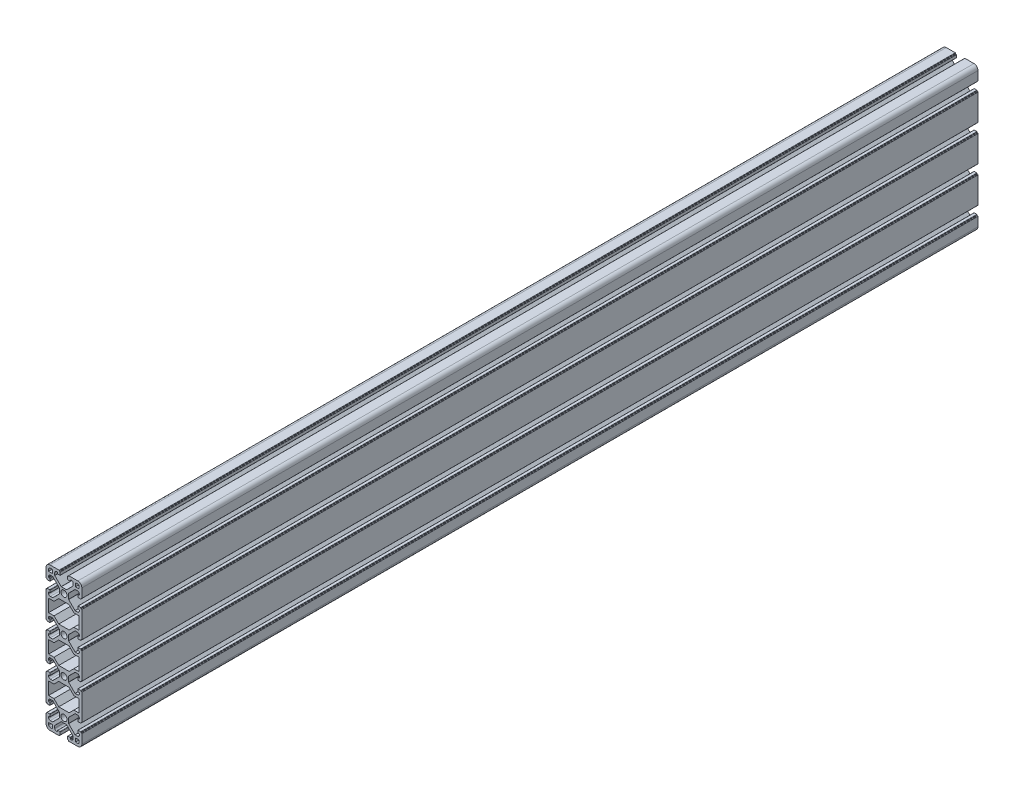
from build123d import *

# Parameters (mm, degrees)
SKETCH_1_R      = 3.4
EXTRUDE_1_DEPTH = 1000


with BuildPart() as part:
    # Эскиз1 → Бобышка-Вытянуть1 (new body)
    with BuildSketch(Plane.XY):
        with BuildLine():
            Line((-20, 10.25), (-20, 15.5))
            ThreePointArc((-20, 15.5), (-18.681980515, 18.681980515), (-15.5, 20))
            Line((-15.5, 20), (-10.25, 20))
            Line((-10.25, 20), (-5.4, 20))
            ThreePointArc((-5.4, 20), (-5.187867966, 19.912132034), (-5.1, 19.7))
            Line((-5.1, 19.7), (-5.1, 19.3))
            ThreePointArc((-5.1, 19.3), (-5.012132034, 19.087867966), (-4.8, 19))
            Line((-4.8, 19), (-4.4, 19))
            ThreePointArc((-4.4, 19), (-4.187867966, 18.912132034), (-4.1, 18.7))
            Line((-4.1, 18.7), (-4.1, 15.8))
            ThreePointArc((-4.1, 15.8), (-4.187867966, 15.587867966), (-4.4, 15.5))
            Line((-4.4, 15.5), (-6.8, 15.5))
            ThreePointArc((-6.8, 15.5), (-7.012132034, 15.587867966), (-7.1, 15.8))
            Line((-7.1, 15.8), (-7.1, 16.9))
            ThreePointArc((-7.1, 16.9), (-7.187867966, 17.112132034), (-7.4, 17.2))
            Line((-7.4, 17.2), (-8.25, 17.2))
            ThreePointArc((-8.25, 17.2), (-9.664213562, 16.614213562), (-10.25, 15.2))
            Line((-10.25, 15.2), (-10.25, 12.574264069))
            ThreePointArc((-10.25, 12.574264069), (-10.22716386, 12.459459039), (-10.162132034, 12.362132034))
            Line((-10.162132034, 12.362132034), (-3.087867966, 5.287867966))
            ThreePointArc((-3.087867966, 5.287867966), (-2.990540961, 5.22283614), (-2.875735931, 5.2))
            Line((-2.875735931, 5.2), (2.875735931, 5.2))
            ThreePointArc((2.875735931, 5.2), (2.990540961, 5.22283614), (3.087867966, 5.287867966))
            Line((3.087867966, 5.287867966), (10.162132034, 12.362132034))
            ThreePointArc((10.162132034, 12.362132034), (10.22716386, 12.459459039), (10.25, 12.574264069))
            Line((10.25, 12.574264069), (10.25, 15.2))
            ThreePointArc((10.25, 15.2), (9.664213562, 16.614213562), (8.25, 17.2))
            Line((8.25, 17.2), (7.4, 17.2))
            ThreePointArc((7.4, 17.2), (7.187867966, 17.112132034), (7.1, 16.9))
            Line((7.1, 16.9), (7.1, 15.8))
            ThreePointArc((7.1, 15.8), (7.012132034, 15.587867966), (6.8, 15.5))
            Line((6.8, 15.5), (4.4, 15.5))
            ThreePointArc((4.4, 15.5), (4.187867966, 15.587867966), (4.1, 15.8))
            Line((4.1, 15.8), (4.1, 18.7))
            ThreePointArc((4.1, 18.7), (4.187867966, 18.912132034), (4.4, 19))
            Line((4.4, 19), (4.8, 19))
            ThreePointArc((4.8, 19), (5.012132034, 19.087867966), (5.1, 19.3))
            Line((5.1, 19.3), (5.1, 19.7))
            ThreePointArc((5.1, 19.7), (5.187867966, 19.912132034), (5.4, 20))
            Line((5.4, 20), (10.25, 20))
            Line((10.25, 20), (15.5, 20))
            ThreePointArc((15.5, 20), (18.681980515, 18.681980515), (20, 15.5))
            Line((20, 15.5), (20, 10.25))
            Line((20, 10.25), (20, 5.4))
            ThreePointArc((20, 5.4), (19.912132034, 5.187867966), (19.7, 5.1))
            Line((19.7, 5.1), (19.3, 5.1))
            ThreePointArc((19.3, 5.1), (19.087867966, 5.012132034), (19, 4.8))
            Line((19, 4.8), (19, 4.4))
            ThreePointArc((19, 4.4), (18.912132034, 4.187867966), (18.7, 4.1))
            Line((18.7, 4.1), (15.8, 4.1))
            ThreePointArc((15.8, 4.1), (15.587867966, 4.187867966), (15.5, 4.4))
            Line((15.5, 4.4), (15.5, 6.8))
            ThreePointArc((15.5, 6.8), (15.587867966, 7.012132034), (15.8, 7.1))
            Line((15.8, 7.1), (16.9, 7.1))
            ThreePointArc((16.9, 7.1), (17.112132034, 7.187867966), (17.2, 7.4))
            Line((17.2, 7.4), (17.2, 8.25))
            ThreePointArc((17.2, 8.25), (16.614213562, 9.664213562), (15.2, 10.25))
            Line((15.2, 10.25), (12.574264069, 10.25))
            ThreePointArc((12.574264069, 10.25), (12.459459039, 10.22716386), (12.362132034, 10.162132034))
            Line((12.362132034, 10.162132034), (5.287867966, 3.087867966))
            ThreePointArc((5.287867966, 3.087867966), (5.22283614, 2.990540961), (5.2, 2.875735931))
            Line((5.2, 2.875735931), (5.2, -2.875735931))
            ThreePointArc((5.2, -2.875735931), (5.22283614, -2.990540961), (5.287867966, -3.087867966))
            Line((5.287867966, -3.087867966), (12.362132034, -10.162132034))
            ThreePointArc((12.362132034, -10.162132034), (12.459459039, -10.22716386), (12.574264069, -10.25))
            Line((12.574264069, -10.25), (15.2, -10.25))
            ThreePointArc((15.2, -10.25), (16.614213562, -9.664213562), (17.2, -8.25))
            Line((17.2, -8.25), (17.2, -7.4))
            ThreePointArc((17.2, -7.4), (17.112132034, -7.187867966), (16.9, -7.1))
            Line((16.9, -7.1), (15.8, -7.1))
            ThreePointArc((15.8, -7.1), (15.587867966, -7.012132034), (15.5, -6.8))
            Line((15.5, -6.8), (15.5, -4.4))
            ThreePointArc((15.5, -4.4), (15.587867966, -4.187867966), (15.8, -4.1))
            Line((15.8, -4.1), (18.7, -4.1))
            ThreePointArc((18.7, -4.1), (18.912132034, -4.187867966), (19, -4.4))
            Line((19, -4.4), (19, -4.8))
            ThreePointArc((19, -4.8), (19.087867966, -5.012132034), (19.3, -5.1))
            Line((19.3, -5.1), (19.7, -5.1))
            ThreePointArc((19.7, -5.1), (19.912132034, -5.187867966), (20, -5.4))
            Line((20, -5.4), (20, -10.25))
            Line((20, -10.25), (20, -29.75))
            Line((20, -29.75), (20, -34.6))
            ThreePointArc((20, -34.6), (19.912132034, -34.812132034), (19.7, -34.9))
            Line((19.7, -34.9), (19.3, -34.9))
            ThreePointArc((19.3, -34.9), (19.087867966, -34.987867966), (19, -35.2))
            Line((19, -35.2), (19, -35.6))
            ThreePointArc((19, -35.6), (18.912132034, -35.812132034), (18.7, -35.9))
            Line((18.7, -35.9), (15.8, -35.9))
            ThreePointArc((15.8, -35.9), (15.587867966, -35.812132034), (15.5, -35.6))
            Line((15.5, -35.6), (15.5, -33.2))
            ThreePointArc((15.5, -33.2), (15.587867966, -32.987867966), (15.8, -32.9))
            Line((15.8, -32.9), (16.9, -32.9))
            ThreePointArc((16.9, -32.9), (17.112132034, -32.812132034), (17.2, -32.6))
            Line((17.2, -32.6), (17.2, -31.75))
            ThreePointArc((17.2, -31.75), (16.614213562, -30.335786438), (15.2, -29.75))
            Line((15.2, -29.75), (12.574264069, -29.75))
            ThreePointArc((12.574264069, -29.75), (12.459459039, -29.77283614), (12.362132034, -29.837867966))
            Line((12.362132034, -29.837867966), (5.287867966, -36.912132034))
            ThreePointArc((5.287867966, -36.912132034), (5.22283614, -37.009459039), (5.2, -37.124264069))
            Line((5.2, -37.124264069), (5.2, -42.875735931))
            ThreePointArc((5.2, -42.875735931), (5.22283614, -42.990540961), (5.287867966, -43.087867966))
            Line((5.287867966, -43.087867966), (12.362132034, -50.162132034))
            ThreePointArc((12.362132034, -50.162132034), (12.459459039, -50.22716386), (12.574264069, -50.25))
            Line((12.574264069, -50.25), (15.2, -50.25))
            ThreePointArc((15.2, -50.25), (16.614213562, -49.664213562), (17.2, -48.25))
            Line((17.2, -48.25), (17.2, -47.4))
            ThreePointArc((17.2, -47.4), (17.112132034, -47.187867966), (16.9, -47.1))
            Line((16.9, -47.1), (15.8, -47.1))
            ThreePointArc((15.8, -47.1), (15.587867966, -47.012132034), (15.5, -46.8))
            Line((15.5, -46.8), (15.5, -44.4))
            ThreePointArc((15.5, -44.4), (15.587867966, -44.187867966), (15.8, -44.1))
            Line((15.8, -44.1), (18.7, -44.1))
            ThreePointArc((18.7, -44.1), (18.912132034, -44.187867966), (19, -44.4))
            Line((19, -44.4), (19, -44.8))
            ThreePointArc((19, -44.8), (19.087867966, -45.012132034), (19.3, -45.1))
            Line((19.3, -45.1), (19.7, -45.1))
            ThreePointArc((19.7, -45.1), (19.912132034, -45.187867966), (20, -45.4))
            Line((20, -45.4), (20, -50.25))
            Line((20, -50.25), (20, -69.75))
            Line((20, -69.75), (20, -74.6))
            ThreePointArc((20, -74.6), (19.912132034, -74.812132034), (19.7, -74.9))
            Line((19.7, -74.9), (19.3, -74.9))
            ThreePointArc((19.3, -74.9), (19.087867966, -74.987867966), (19, -75.2))
            Line((19, -75.2), (19, -75.6))
            ThreePointArc((19, -75.6), (18.912132034, -75.812132034), (18.7, -75.9))
            Line((18.7, -75.9), (15.8, -75.9))
            ThreePointArc((15.8, -75.9), (15.587867966, -75.812132034), (15.5, -75.6))
            Line((15.5, -75.6), (15.5, -73.2))
            ThreePointArc((15.5, -73.2), (15.587867966, -72.987867966), (15.8, -72.9))
            Line((15.8, -72.9), (16.9, -72.9))
            ThreePointArc((16.9, -72.9), (17.112132034, -72.812132034), (17.2, -72.6))
            Line((17.2, -72.6), (17.2, -71.75))
            ThreePointArc((17.2, -71.75), (16.614213562, -70.335786438), (15.2, -69.75))
            Line((15.2, -69.75), (12.574264069, -69.75))
            ThreePointArc((12.574264069, -69.75), (12.459459039, -69.77283614), (12.362132034, -69.837867966))
            Line((12.362132034, -69.837867966), (5.287867966, -76.912132034))
            ThreePointArc((5.287867966, -76.912132034), (5.22283614, -77.009459039), (5.2, -77.124264069))
            Line((5.2, -77.124264069), (5.2, -82.875735931))
            ThreePointArc((5.2, -82.875735931), (5.22283614, -82.990540961), (5.287867966, -83.087867966))
            Line((5.287867966, -83.087867966), (12.362132034, -90.162132034))
            ThreePointArc((12.362132034, -90.162132034), (12.459459039, -90.22716386), (12.574264069, -90.25))
            Line((12.574264069, -90.25), (15.2, -90.25))
            ThreePointArc((15.2, -90.25), (16.614213562, -89.664213562), (17.2, -88.25))
            Line((17.2, -88.25), (17.2, -87.4))
            ThreePointArc((17.2, -87.4), (17.112132034, -87.187867966), (16.9, -87.1))
            Line((16.9, -87.1), (15.8, -87.1))
            ThreePointArc((15.8, -87.1), (15.587867966, -87.012132034), (15.5, -86.8))
            Line((15.5, -86.8), (15.5, -84.4))
            ThreePointArc((15.5, -84.4), (15.587867966, -84.187867966), (15.8, -84.1))
            Line((15.8, -84.1), (18.7, -84.1))
            ThreePointArc((18.7, -84.1), (18.912132034, -84.187867966), (19, -84.4))
            Line((19, -84.4), (19, -84.8))
            ThreePointArc((19, -84.8), (19.087867966, -85.012132034), (19.3, -85.1))
            Line((19.3, -85.1), (19.7, -85.1))
            ThreePointArc((19.7, -85.1), (19.912132034, -85.187867966), (20, -85.4))
            Line((20, -85.4), (20, -90.25))
            Line((20, -90.25), (20, -109.75))
            Line((20, -109.75), (20, -114.6))
            ThreePointArc((20, -114.6), (19.912132034, -114.812132034), (19.7, -114.9))
            Line((19.7, -114.9), (19.3, -114.9))
            ThreePointArc((19.3, -114.9), (19.087867966, -114.987867966), (19, -115.2))
            Line((19, -115.2), (19, -115.6))
            ThreePointArc((19, -115.6), (18.912132034, -115.812132034), (18.7, -115.9))
            Line((18.7, -115.9), (15.8, -115.9))
            ThreePointArc((15.8, -115.9), (15.587867966, -115.812132034), (15.5, -115.6))
            Line((15.5, -115.6), (15.5, -113.2))
            ThreePointArc((15.5, -113.2), (15.587867966, -112.987867966), (15.8, -112.9))
            Line((15.8, -112.9), (16.9, -112.9))
            ThreePointArc((16.9, -112.9), (17.112132034, -112.812132034), (17.2, -112.6))
            Line((17.2, -112.6), (17.2, -111.75))
            ThreePointArc((17.2, -111.75), (16.614213562, -110.335786438), (15.2, -109.75))
            Line((15.2, -109.75), (12.574264069, -109.75))
            ThreePointArc((12.574264069, -109.75), (12.459459039, -109.77283614), (12.362132034, -109.837867966))
            Line((12.362132034, -109.837867966), (5.287867966, -116.912132034))
            ThreePointArc((5.287867966, -116.912132034), (5.22283614, -117.009459039), (5.2, -117.124264069))
            Line((5.2, -117.124264069), (5.2, -122.875735931))
            ThreePointArc((5.2, -122.875735931), (5.22283614, -122.990540961), (5.287867966, -123.087867966))
            Line((5.287867966, -123.087867966), (12.362132034, -130.162132034))
            ThreePointArc((12.362132034, -130.162132034), (12.459459039, -130.22716386), (12.574264069, -130.25))
            Line((12.574264069, -130.25), (15.2, -130.25))
            ThreePointArc((15.2, -130.25), (16.614213562, -129.664213562), (17.2, -128.25))
            Line((17.2, -128.25), (17.2, -127.4))
            ThreePointArc((17.2, -127.4), (17.112132034, -127.187867966), (16.9, -127.1))
            Line((16.9, -127.1), (15.8, -127.1))
            ThreePointArc((15.8, -127.1), (15.587867966, -127.012132034), (15.5, -126.8))
            Line((15.5, -126.8), (15.5, -124.4))
            ThreePointArc((15.5, -124.4), (15.587867966, -124.187867966), (15.8, -124.1))
            Line((15.8, -124.1), (18.7, -124.1))
            ThreePointArc((18.7, -124.1), (18.912132034, -124.187867966), (19, -124.4))
            Line((19, -124.4), (19, -124.8))
            ThreePointArc((19, -124.8), (19.087867966, -125.012132034), (19.3, -125.1))
            Line((19.3, -125.1), (19.7, -125.1))
            ThreePointArc((19.7, -125.1), (19.912132034, -125.187867966), (20, -125.4))
            Line((20, -125.4), (20, -130.25))
            Line((20, -130.25), (20, -135.5))
            ThreePointArc((20, -135.5), (18.681980515, -138.681980515), (15.5, -140))
            Line((15.5, -140), (10.25, -140))
            Line((10.25, -140), (5.4, -140))
            ThreePointArc((5.4, -140), (5.187867966, -139.912132034), (5.1, -139.7))
            Line((5.1, -139.7), (5.1, -139.3))
            ThreePointArc((5.1, -139.3), (5.012132034, -139.087867966), (4.8, -139))
            Line((4.8, -139), (4.4, -139))
            ThreePointArc((4.4, -139), (4.187867966, -138.912132034), (4.1, -138.7))
            Line((4.1, -138.7), (4.1, -135.8))
            ThreePointArc((4.1, -135.8), (4.187867966, -135.587867966), (4.4, -135.5))
            Line((4.4, -135.5), (6.8, -135.5))
            ThreePointArc((6.8, -135.5), (7.012132034, -135.587867966), (7.1, -135.8))
            Line((7.1, -135.8), (7.1, -136.9))
            ThreePointArc((7.1, -136.9), (7.187867966, -137.112132034), (7.4, -137.2))
            Line((7.4, -137.2), (8.25, -137.2))
            ThreePointArc((8.25, -137.2), (9.664213562, -136.614213562), (10.25, -135.2))
            Line((10.25, -135.2), (10.25, -132.574264069))
            ThreePointArc((10.25, -132.574264069), (10.22716386, -132.459459039), (10.162132034, -132.362132034))
            Line((10.162132034, -132.362132034), (3.087867966, -125.287867966))
            ThreePointArc((3.087867966, -125.287867966), (2.990540961, -125.22283614), (2.875735931, -125.2))
            Line((2.875735931, -125.2), (-2.875735931, -125.2))
            ThreePointArc((-2.875735931, -125.2), (-2.990540961, -125.22283614), (-3.087867966, -125.287867966))
            Line((-3.087867966, -125.287867966), (-10.162132034, -132.362132034))
            ThreePointArc((-10.162132034, -132.362132034), (-10.22716386, -132.459459039), (-10.25, -132.574264069))
            Line((-10.25, -132.574264069), (-10.25, -135.2))
            ThreePointArc((-10.25, -135.2), (-9.664213562, -136.614213562), (-8.25, -137.2))
            Line((-8.25, -137.2), (-7.4, -137.2))
            ThreePointArc((-7.4, -137.2), (-7.187867966, -137.112132034), (-7.1, -136.9))
            Line((-7.1, -136.9), (-7.1, -135.8))
            ThreePointArc((-7.1, -135.8), (-7.012132034, -135.587867966), (-6.8, -135.5))
            Line((-6.8, -135.5), (-4.4, -135.5))
            ThreePointArc((-4.4, -135.5), (-4.187867966, -135.587867966), (-4.1, -135.8))
            Line((-4.1, -135.8), (-4.1, -138.7))
            ThreePointArc((-4.1, -138.7), (-4.187867966, -138.912132034), (-4.4, -139))
            Line((-4.4, -139), (-4.8, -139))
            ThreePointArc((-4.8, -139), (-5.012132034, -139.087867966), (-5.1, -139.3))
            Line((-5.1, -139.3), (-5.1, -139.7))
            ThreePointArc((-5.1, -139.7), (-5.187867966, -139.912132034), (-5.4, -140))
            Line((-5.4, -140), (-10.25, -140))
            Line((-10.25, -140), (-15.5, -140))
            ThreePointArc((-15.5, -140), (-18.681980515, -138.681980515), (-20, -135.5))
            Line((-20, -135.5), (-20, -130.25))
            Line((-20, -130.25), (-20, -125.4))
            ThreePointArc((-20, -125.4), (-19.912132034, -125.187867966), (-19.7, -125.1))
            Line((-19.7, -125.1), (-19.3, -125.1))
            ThreePointArc((-19.3, -125.1), (-19.087867966, -125.012132034), (-19, -124.8))
            Line((-19, -124.8), (-19, -124.4))
            ThreePointArc((-19, -124.4), (-18.912132034, -124.187867966), (-18.7, -124.1))
            Line((-18.7, -124.1), (-15.8, -124.1))
            ThreePointArc((-15.8, -124.1), (-15.587867966, -124.187867966), (-15.5, -124.4))
            Line((-15.5, -124.4), (-15.5, -126.8))
            ThreePointArc((-15.5, -126.8), (-15.587867966, -127.012132034), (-15.8, -127.1))
            Line((-15.8, -127.1), (-16.9, -127.1))
            ThreePointArc((-16.9, -127.1), (-17.112132034, -127.187867966), (-17.2, -127.4))
            Line((-17.2, -127.4), (-17.2, -128.25))
            ThreePointArc((-17.2, -128.25), (-16.614213562, -129.664213562), (-15.2, -130.25))
            Line((-15.2, -130.25), (-12.574264069, -130.25))
            ThreePointArc((-12.574264069, -130.25), (-12.459459039, -130.22716386), (-12.362132034, -130.162132034))
            Line((-12.362132034, -130.162132034), (-5.287867966, -123.087867966))
            ThreePointArc((-5.287867966, -123.087867966), (-5.22283614, -122.990540961), (-5.2, -122.875735931))
            Line((-5.2, -122.875735931), (-5.2, -117.124264069))
            ThreePointArc((-5.2, -117.124264069), (-5.22283614, -117.009459039), (-5.287867966, -116.912132034))
            Line((-5.287867966, -116.912132034), (-12.362132034, -109.837867966))
            ThreePointArc((-12.362132034, -109.837867966), (-12.459459039, -109.77283614), (-12.574264069, -109.75))
            Line((-12.574264069, -109.75), (-15.2, -109.75))
            ThreePointArc((-15.2, -109.75), (-16.614213562, -110.335786438), (-17.2, -111.75))
            Line((-17.2, -111.75), (-17.2, -112.6))
            ThreePointArc((-17.2, -112.6), (-17.112132034, -112.812132034), (-16.9, -112.9))
            Line((-16.9, -112.9), (-15.8, -112.9))
            ThreePointArc((-15.8, -112.9), (-15.587867966, -112.987867966), (-15.5, -113.2))
            Line((-15.5, -113.2), (-15.5, -115.6))
            ThreePointArc((-15.5, -115.6), (-15.587867966, -115.812132034), (-15.8, -115.9))
            Line((-15.8, -115.9), (-18.7, -115.9))
            ThreePointArc((-18.7, -115.9), (-18.912132034, -115.812132034), (-19, -115.6))
            Line((-19, -115.6), (-19, -115.2))
            ThreePointArc((-19, -115.2), (-19.087867966, -114.987867966), (-19.3, -114.9))
            Line((-19.3, -114.9), (-19.7, -114.9))
            ThreePointArc((-19.7, -114.9), (-19.912132034, -114.812132034), (-20, -114.6))
            Line((-20, -114.6), (-20, -109.75))
            Line((-20, -109.75), (-20, -90.25))
            Line((-20, -90.25), (-20, -85.4))
            ThreePointArc((-20, -85.4), (-19.912132034, -85.187867966), (-19.7, -85.1))
            Line((-19.7, -85.1), (-19.3, -85.1))
            ThreePointArc((-19.3, -85.1), (-19.087867966, -85.012132034), (-19, -84.8))
            Line((-19, -84.8), (-19, -84.4))
            ThreePointArc((-19, -84.4), (-18.912132034, -84.187867966), (-18.7, -84.1))
            Line((-18.7, -84.1), (-15.8, -84.1))
            ThreePointArc((-15.8, -84.1), (-15.587867966, -84.187867966), (-15.5, -84.4))
            Line((-15.5, -84.4), (-15.5, -86.8))
            ThreePointArc((-15.5, -86.8), (-15.587867966, -87.012132034), (-15.8, -87.1))
            Line((-15.8, -87.1), (-16.9, -87.1))
            ThreePointArc((-16.9, -87.1), (-17.112132034, -87.187867966), (-17.2, -87.4))
            Line((-17.2, -87.4), (-17.2, -88.25))
            ThreePointArc((-17.2, -88.25), (-16.614213562, -89.664213562), (-15.2, -90.25))
            Line((-15.2, -90.25), (-12.574264069, -90.25))
            ThreePointArc((-12.574264069, -90.25), (-12.459459039, -90.22716386), (-12.362132034, -90.162132034))
            Line((-12.362132034, -90.162132034), (-5.287867966, -83.087867966))
            ThreePointArc((-5.287867966, -83.087867966), (-5.22283614, -82.990540961), (-5.2, -82.875735931))
            Line((-5.2, -82.875735931), (-5.2, -77.124264069))
            ThreePointArc((-5.2, -77.124264069), (-5.22283614, -77.009459039), (-5.287867966, -76.912132034))
            Line((-5.287867966, -76.912132034), (-12.362132034, -69.837867966))
            ThreePointArc((-12.362132034, -69.837867966), (-12.459459039, -69.77283614), (-12.574264069, -69.75))
            Line((-12.574264069, -69.75), (-15.2, -69.75))
            ThreePointArc((-15.2, -69.75), (-16.614213562, -70.335786438), (-17.2, -71.75))
            Line((-17.2, -71.75), (-17.2, -72.6))
            ThreePointArc((-17.2, -72.6), (-17.112132034, -72.812132034), (-16.9, -72.9))
            Line((-16.9, -72.9), (-15.8, -72.9))
            ThreePointArc((-15.8, -72.9), (-15.587867966, -72.987867966), (-15.5, -73.2))
            Line((-15.5, -73.2), (-15.5, -75.6))
            ThreePointArc((-15.5, -75.6), (-15.587867966, -75.812132034), (-15.8, -75.9))
            Line((-15.8, -75.9), (-18.7, -75.9))
            ThreePointArc((-18.7, -75.9), (-18.912132034, -75.812132034), (-19, -75.6))
            Line((-19, -75.6), (-19, -75.2))
            ThreePointArc((-19, -75.2), (-19.087867966, -74.987867966), (-19.3, -74.9))
            Line((-19.3, -74.9), (-19.7, -74.9))
            ThreePointArc((-19.7, -74.9), (-19.912132034, -74.812132034), (-20, -74.6))
            Line((-20, -74.6), (-20, -69.75))
            Line((-20, -69.75), (-20, -50.25))
            Line((-20, -50.25), (-20, -45.4))
            ThreePointArc((-20, -45.4), (-19.912132034, -45.187867966), (-19.7, -45.1))
            Line((-19.7, -45.1), (-19.3, -45.1))
            ThreePointArc((-19.3, -45.1), (-19.087867966, -45.012132034), (-19, -44.8))
            Line((-19, -44.8), (-19, -44.4))
            ThreePointArc((-19, -44.4), (-18.912132034, -44.187867966), (-18.7, -44.1))
            Line((-18.7, -44.1), (-15.8, -44.1))
            ThreePointArc((-15.8, -44.1), (-15.587867966, -44.187867966), (-15.5, -44.4))
            Line((-15.5, -44.4), (-15.5, -46.8))
            ThreePointArc((-15.5, -46.8), (-15.587867966, -47.012132034), (-15.8, -47.1))
            Line((-15.8, -47.1), (-16.9, -47.1))
            ThreePointArc((-16.9, -47.1), (-17.112132034, -47.187867966), (-17.2, -47.4))
            Line((-17.2, -47.4), (-17.2, -48.25))
            ThreePointArc((-17.2, -48.25), (-16.614213562, -49.664213562), (-15.2, -50.25))
            Line((-15.2, -50.25), (-12.574264069, -50.25))
            ThreePointArc((-12.574264069, -50.25), (-12.459459039, -50.22716386), (-12.362132034, -50.162132034))
            Line((-12.362132034, -50.162132034), (-5.287867966, -43.087867966))
            ThreePointArc((-5.287867966, -43.087867966), (-5.22283614, -42.990540961), (-5.2, -42.875735931))
            Line((-5.2, -42.875735931), (-5.2, -37.124264069))
            ThreePointArc((-5.2, -37.124264069), (-5.22283614, -37.009459039), (-5.287867966, -36.912132034))
            Line((-5.287867966, -36.912132034), (-12.362132034, -29.837867966))
            ThreePointArc((-12.362132034, -29.837867966), (-12.459459039, -29.77283614), (-12.574264069, -29.75))
            Line((-12.574264069, -29.75), (-15.2, -29.75))
            ThreePointArc((-15.2, -29.75), (-16.614213562, -30.335786438), (-17.2, -31.75))
            Line((-17.2, -31.75), (-17.2, -32.6))
            ThreePointArc((-17.2, -32.6), (-17.112132034, -32.812132034), (-16.9, -32.9))
            Line((-16.9, -32.9), (-15.8, -32.9))
            ThreePointArc((-15.8, -32.9), (-15.587867966, -32.987867966), (-15.5, -33.2))
            Line((-15.5, -33.2), (-15.5, -35.6))
            ThreePointArc((-15.5, -35.6), (-15.587867966, -35.812132034), (-15.8, -35.9))
            Line((-15.8, -35.9), (-18.7, -35.9))
            ThreePointArc((-18.7, -35.9), (-18.912132034, -35.812132034), (-19, -35.6))
            Line((-19, -35.6), (-19, -35.2))
            ThreePointArc((-19, -35.2), (-19.087867966, -34.987867966), (-19.3, -34.9))
            Line((-19.3, -34.9), (-19.7, -34.9))
            ThreePointArc((-19.7, -34.9), (-19.912132034, -34.812132034), (-20, -34.6))
            Line((-20, -34.6), (-20, -29.75))
            Line((-20, -29.75), (-20, -10.25))
            Line((-20, -10.25), (-20, -5.4))
            ThreePointArc((-20, -5.4), (-19.912132034, -5.187867966), (-19.7, -5.1))
            Line((-19.7, -5.1), (-19.3, -5.1))
            ThreePointArc((-19.3, -5.1), (-19.087867966, -5.012132034), (-19, -4.8))
            Line((-19, -4.8), (-19, -4.4))
            ThreePointArc((-19, -4.4), (-18.912132034, -4.187867966), (-18.7, -4.1))
            Line((-18.7, -4.1), (-15.8, -4.1))
            ThreePointArc((-15.8, -4.1), (-15.587867966, -4.187867966), (-15.5, -4.4))
            Line((-15.5, -4.4), (-15.5, -6.8))
            ThreePointArc((-15.5, -6.8), (-15.587867966, -7.012132034), (-15.8, -7.1))
            Line((-15.8, -7.1), (-16.9, -7.1))
            ThreePointArc((-16.9, -7.1), (-17.112132034, -7.187867966), (-17.2, -7.4))
            Line((-17.2, -7.4), (-17.2, -8.25))
            ThreePointArc((-17.2, -8.25), (-16.614213562, -9.664213562), (-15.2, -10.25))
            Line((-15.2, -10.25), (-12.574264069, -10.25))
            ThreePointArc((-12.574264069, -10.25), (-12.459459039, -10.22716386), (-12.362132034, -10.162132034))
            Line((-12.362132034, -10.162132034), (-5.287867966, -3.087867966))
            ThreePointArc((-5.287867966, -3.087867966), (-5.22283614, -2.990540961), (-5.2, -2.875735931))
            Line((-5.2, -2.875735931), (-5.2, 2.875735931))
            ThreePointArc((-5.2, 2.875735931), (-5.22283614, 2.990540961), (-5.287867966, 3.087867966))
            Line((-5.287867966, 3.087867966), (-12.362132034, 10.162132034))
            ThreePointArc((-12.362132034, 10.162132034), (-12.459459039, 10.22716386), (-12.574264069, 10.25))
            Line((-12.574264069, 10.25), (-15.2, 10.25))
            ThreePointArc((-15.2, 10.25), (-16.614213562, 9.664213562), (-17.2, 8.25))
            Line((-17.2, 8.25), (-17.2, 7.4))
            ThreePointArc((-17.2, 7.4), (-17.112132034, 7.187867966), (-16.9, 7.1))
            Line((-16.9, 7.1), (-15.8, 7.1))
            ThreePointArc((-15.8, 7.1), (-15.587867966, 7.012132034), (-15.5, 6.8))
            Line((-15.5, 6.8), (-15.5, 4.4))
            ThreePointArc((-15.5, 4.4), (-15.587867966, 4.187867966), (-15.8, 4.1))
            Line((-15.8, 4.1), (-18.7, 4.1))
            ThreePointArc((-18.7, 4.1), (-18.912132034, 4.187867966), (-19, 4.4))
            Line((-19, 4.4), (-19, 4.8))
            ThreePointArc((-19, 4.8), (-19.087867966, 5.012132034), (-19.3, 5.1))
            Line((-19.3, 5.1), (-19.7, 5.1))
            ThreePointArc((-19.7, 5.1), (-19.912132034, 5.187867966), (-20, 5.4))
            Line((-20, 5.4), (-20, 10.25))
        make_face()
        Circle(SKETCH_1_R, mode=Mode.SUBTRACT)
        with Locations((0, -40)):
            Circle(SKETCH_1_R, mode=Mode.SUBTRACT)
        with Locations((0, -80)):
            Circle(SKETCH_1_R, mode=Mode.SUBTRACT)
        with Locations((0, -120)):
            Circle(SKETCH_1_R, mode=Mode.SUBTRACT)
        with BuildLine():
            Line((-13, 13), (-17, 13))
            Line((-17, 13), (-17, 15.5))
            ThreePointArc((-17, 15.5), (-16.560660172, 16.560660172), (-15.5, 17))
            Line((-15.5, 17), (-13, 17))
            Line((-13, 17), (-13, 13))
        make_face(mode=Mode.SUBTRACT)
        with BuildLine():
            Line((13, 13), (17, 13))
            Line((17, 13), (17, 15.5))
            ThreePointArc((17, 15.5), (16.560660172, 16.560660172), (15.5, 17))
            Line((15.5, 17), (13, 17))
            Line((13, 17), (13, 13))
        make_face(mode=Mode.SUBTRACT)
        Polygon((-17.1, -27), (-17.1, -13), (-11.098780669, -13), (-5.798780669, -7.7), (5.798780669, -7.7), (11.098780669, -13), (17.1, -13), (17.1, -27), (11.098780669, -27), (5.798780669, -32.3), (-5.798780669, -32.3), (-11.098780669, -27), align=None, mode=Mode.SUBTRACT)
        Polygon((-11.098780669, -67), (-5.798780669, -72.3), (5.798780669, -72.3), (11.098780669, -67), (17.1, -67), (17.1, -53), (11.098780669, -53), (5.798780669, -47.7), (-5.798780669, -47.7), (-11.098780669, -53), (-17.1, -53), (-17.1, -67), align=None, mode=Mode.SUBTRACT)
        Polygon((-11.098780669, -107), (-5.798780669, -112.3), (5.798780669, -112.3), (11.098780669, -107), (17.1, -107), (17.1, -93), (11.098780669, -93), (5.798780669, -87.7), (-5.798780669, -87.7), (-11.098780669, -93), (-17.1, -93), (-17.1, -107), align=None, mode=Mode.SUBTRACT)
        with BuildLine():
            Line((13, -133), (13, -137))
            Line((13, -137), (15.5, -137))
            ThreePointArc((15.5, -137), (16.560660172, -136.560660172), (17, -135.5))
            Line((17, -135.5), (17, -133))
            Line((17, -133), (13, -133))
        make_face(mode=Mode.SUBTRACT)
        with BuildLine():
            Line((-13, -137), (-15.5, -137))
            ThreePointArc((-15.5, -137), (-16.560660172, -136.560660172), (-17, -135.5))
            Line((-17, -135.5), (-17, -133))
            Line((-17, -133), (-13, -133))
            Line((-13, -133), (-13, -137))
        make_face(mode=Mode.SUBTRACT)
    extrude(amount=EXTRUDE_1_DEPTH)


solid = part.part
